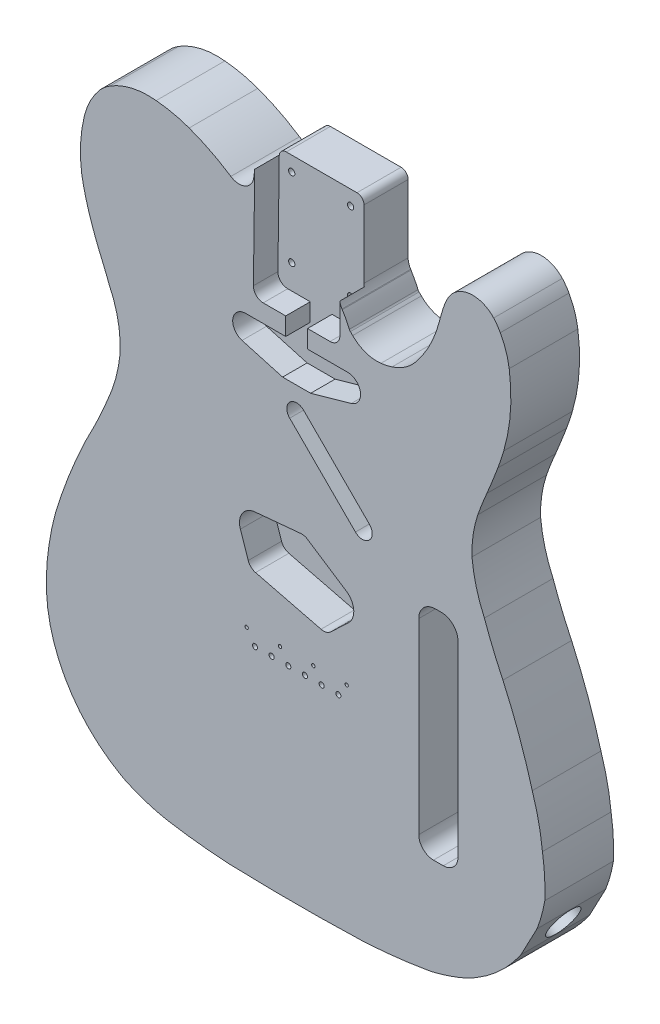
from build123d import *

# Parameters (mm, degrees)
EXTRUDE1_DEPTH     = 44.45
CUT_EXTRUDE1_DEPTH = 15.875
CUT_EXTRUDE2_DEPTH = 15.875
CUT_EXTRUDE3_DEPTH = 21.59
CUT_EXTRUDE4_DEPTH = 38.1
SKETCH7_R          = 2.032
SKETCH7_R_2        = 1.651
SKETCH7_R_3        = 1.0795
CUT_EXTRUDE5_DEPTH = 45.45
SKETCH9_R          = 10.4775
CUT_EXTRUDE6_DEPTH = 60.96


with BuildPart() as part:
    # Sketch1 → Extrude1 (new body)
    with BuildSketch(Plane.XY):
        with BuildLine():
            Line((292.199188308, -149.018420949), (292.199188308, -105.080789749))
            ThreePointArc((292.199188308, -105.080789749), (290.860080512, -101.847897546), (287.627188308, -100.508789749))
            Line((287.627188308, -100.508789749), (241.859817308, -100.508789749))
            ThreePointArc((241.859817308, -100.508789749), (238.832325903, -101.654789196), (237.322552553, -104.518284153))
            Line((237.322552553, -104.518284153), (236.701316073, -109.52926873))
            ThreePointArc((236.701316073, -109.52926873), (231.168774634, -117.069145619), (221.847963335, -116.306757925))
            ThreePointArc((221.847963335, -116.306757925), (208.754430906, -108.681109765), (194.846389938, -102.667999276))
            ThreePointArc((194.846389938, -102.667999276), (184.33706687, -99.609971872), (173.515607417, -97.968808186))
            ThreePointArc((173.515607417, -97.968808186), (158.033643634, -98.861943823), (143.665987646, -104.697983172))
            ThreePointArc((143.665987646, -104.697983172), (140.408838277, -107.058481962), (137.445598788, -109.778810669))
            ThreePointArc((137.445598788, -109.778810669), (131.043721763, -119.123880284), (127.035981804, -129.718802463))
            ThreePointArc((127.035981804, -129.718802463), (124.573432967, -146.269656884), (125.255619962, -162.988794116))
            ThreePointArc((125.255619962, -162.988794116), (127.242538349, -172.460797738), (129.825215128, -181.787987987))
            ThreePointArc((129.825215128, -181.787987987), (133.075015811, -191.465362925), (136.805999876, -200.967602033))
            ThreePointArc((136.805999876, -200.967602033), (140.009351293, -208.552159349), (143.036403771, -216.208785452))
            ThreePointArc((143.036403771, -216.208785452), (148.821671734, -233.475789286), (150.145583831, -251.638002906))
            ThreePointArc((150.145583831, -251.638002906), (147.267654281, -267.095111542), (141.885601169, -281.867998538))
            ThreePointArc((141.885601169, -281.867998538), (138.15011329, -290.562901746), (134.146412963, -299.137608457))
            ThreePointArc((134.146412963, -299.137608457), (121.785922582, -324.908171995), (111.535599896, -351.588399738))
            ThreePointArc((111.535599896, -351.588399738), (106.985107058, -366.822863837), (104.046020061, -382.448408598))
            ThreePointArc((104.046020061, -382.448408598), (102.647449975, -395.681700125), (102.514778175, -408.988029488))
            ThreePointArc((102.514778175, -408.988029488), (116.491997059, -454.558227502), (150.7976326, -487.650960312))
            ThreePointArc((150.7976326, -487.650960312), (153.132813702, -488.891966769), (155.529411112, -490.009772055))
            ThreePointArc((155.529411112, -490.009772055), (162.119332045, -492.66041759), (168.847113622, -494.938560412))
            ThreePointArc((168.847113622, -494.938560412), (175.41675582, -496.721647355), (182.091053802, -498.06080534))
            ThreePointArc((182.091053802, -498.06080534), (201.284365127, -500.712124037), (220.593569016, -502.314414768))
            ThreePointArc((220.593569016, -502.314414768), (221.005809518, -502.335099855), (221.418249918, -502.351317756))
            ThreePointArc((221.418249918, -502.351317756), (264.647051031, -503.080364835), (307.875618661, -502.337602376))
            ThreePointArc((307.875618661, -502.337602376), (328.927693445, -500.563755223), (349.837334812, -497.543277726))
            ThreePointArc((349.837334812, -497.543277726), (351.598276471, -497.203125432), (353.34611347, -496.801024785))
            ThreePointArc((353.34611347, -496.801024785), (361.755549825, -494.399047207), (369.979692546, -491.423884594))
            ThreePointArc((369.979692546, -491.423884594), (375.398528429, -489.000609473), (380.612291985, -486.162879004))
            ThreePointArc((380.612291985, -486.162879004), (396.681938677, -474.024490792), (409.729890716, -458.684185685))
            Line((409.729890716, -458.684185685), (420.094055916, -439.023188685))
            ThreePointArc((420.094055916, -439.023188685), (423.063561292, -430.01344484), (425.122156967, -420.753011255))
            ThreePointArc((425.122156967, -420.753011255), (425.004343862, -407.337993061), (423.600912787, -393.996067626))
            ThreePointArc((423.600912787, -393.996067626), (421.10111713, -378.394798828), (417, -363.136050363))
            ThreePointArc((417, -363.136050363), (408.529943954, -336.537553481), (398, -310.685238959))
            ThreePointArc((398, -310.685238959), (391.630728219, -296.430381849), (386, -281.867982529))
            ThreePointArc((386, -281.867982529), (380.726878313, -267.085540483), (377.952, -251.638001665))
            ThreePointArc((377.952, -251.638001665), (378.714214467, -238.675334685), (381.762, -226.053024696))
            ThreePointArc((381.762, -226.053024696), (384.539198732, -218.556898426), (387.604315044, -211.173822925))
            ThreePointArc((387.604315044, -211.173822925), (391.254222849, -202.284529655), (394.711732353, -193.318650453))
            ThreePointArc((394.711732353, -193.318650453), (396.712754261, -187.660629455), (398.51083823, -181.934881964))
            ThreePointArc((398.51083823, -181.934881964), (402.850474904, -158.142443784), (402.069055883, -133.970105351))
            ThreePointArc((402.069055883, -133.970105351), (399.985802716, -125.076495888), (396.320319987, -116.70986757))
            ThreePointArc((396.320319987, -116.70986757), (394.334175573, -113.548332568), (392.000790649, -110.63364768))
            ThreePointArc((392.000790649, -110.63364768), (377.452238099, -104.634981093), (363.691267002, -112.269118675))
            ThreePointArc((363.691267002, -112.269118675), (361.726956799, -115.496521241), (360.217685454, -118.960152558))
            ThreePointArc((360.217685454, -118.960152558), (358.444494216, -124.360677397), (356.931483202, -129.839789858))
            ThreePointArc((356.931483202, -129.839789858), (350.978861449, -145.938115534), (341.692412278, -160.372507003))
            ThreePointArc((341.692412278, -160.372507003), (334.73699249, -166.788775863), (326.235196527, -170.94399378))
            ThreePointArc((326.235196527, -170.94399378), (322.667875689, -171.899746908), (319.025876709, -172.512189097))
            ThreePointArc((319.025876709, -172.512189097), (309.134941175, -171.428010076), (300.736447938, -166.092153889))
            ThreePointArc((300.736447938, -166.092153889), (300.007266015, -165.356748256), (299.271136815, -164.6282968))
            ThreePointArc((299.271136815, -164.6282968), (298.881114017, -164.165142154), (298.586108838, -163.636368144))
            ThreePointArc((298.586108838, -163.636368144), (296.462851387, -159.222894193), (294.036002675, -154.968792661))
            ThreePointArc((294.036002675, -154.968792661), (293.913775031, -154.790050379), (293.795194926, -154.608867711))
            ThreePointArc((293.795194926, -154.608867711), (292.597959361, -151.927620431), (292.199188308, -149.018420949))
        make_face()
    extrude(amount=EXTRUDE1_DEPTH)

    # Sketch3 → Cut-Extrude1 (cut)
    with BuildSketch(Plane.XY.offset(44.45)):
        with BuildLine():
            Line((236.449845908, -170.314898549), (237.322552553, -104.518284153))
            ThreePointArc((237.322552553, -104.518284153), (238.832325903, -101.654789196), (241.859817308, -100.508789749))
            Line((241.859817308, -100.508789749), (287.627188308, -100.508789749))
            ThreePointArc((287.627188308, -100.508789749), (290.860080512, -101.847897546), (292.199188308, -105.080789749))
            Line((292.199188308, -105.080789749), (292.442550838, -170.3148977))
            ThreePointArc((292.442550838, -170.3148977), (290.616739776, -174.866113366), (286.093256908, -176.759589749))
            Line((286.093256908, -176.759589749), (271.507408508, -176.759589749))
            Line((271.507408508, -176.759589749), (271.507408508, -188.316589749))
            Line((271.507408508, -188.316589749), (297.505299108, -188.316589749))
            ThreePointArc((297.505299108, -188.316589749), (305.755367231, -195.487932258), (299.802423969, -204.656042419))
            Line((299.802423969, -204.656042419), (273.524828908, -212.065589749))
            Line((273.524828908, -212.065589749), (255.367537308, -212.065589749))
            Line((255.367537308, -212.065589749), (229.089966669, -204.656042138))
            ThreePointArc((229.089966669, -204.656042138), (223.137024456, -195.487931754), (231.387092508, -188.316589749))
            Line((231.387092508, -188.316589749), (257.385008508, -188.316589749))
            Line((257.385008508, -188.316589749), (257.385008508, -176.759589749))
            Line((257.385008508, -176.759589749), (242.799134708, -176.759589749))
            ThreePointArc((242.799134708, -176.759589749), (238.275655477, -174.866111836), (236.449845908, -170.314898549))
        make_face()
    extrude(amount=-CUT_EXTRUDE1_DEPTH, mode=Mode.SUBTRACT)

    # Sketch4 → Cut-Extrude2 (cut)
    with BuildSketch(Plane.XY.offset(44.45)):
        with BuildLine():
            Line((259.956078591, -232.811718112), (302.5224836, -275.3781386))
            ThreePointArc((302.5224836, -275.3781386), (311.5027425, -275.3781513), (311.5027552, -266.3978924))
            Line((311.5027552, -266.3978924), (268.936335809, -223.831463088))
            ThreePointArc((268.936335809, -223.831463088), (259.956079688, -223.831461991), (259.956078591, -232.811718112))
        make_face()
    extrude(amount=-CUT_EXTRUDE2_DEPTH, mode=Mode.SUBTRACT)

    # Sketch5 → Cut-Extrude3 (cut)
    with BuildSketch(Plane.XY.offset(44.45)):
        with BuildLine():
            Line((228.0253758, -311.0069726), (233.0908216, -326.0407246))
            ThreePointArc((233.0908216, -326.0407246), (234.905674363, -328.839037735), (237.841094697, -330.422563679))
            Line((237.841094697, -330.422563679), (280.248995, -340.9960414))
            ThreePointArc((280.248995, -340.9960414), (283.58425184, -340.975976581), (286.500413487, -339.357229523))
            Line((286.500413487, -339.357229523), (298.0308492, -328.4612938))
            ThreePointArc((298.0308492, -328.4612938), (301.409166684, -319.564297135), (296.527090326, -311.395153414))
            Line((296.527090326, -311.395153414), (271.5010572, -294.9508198))
            ThreePointArc((271.5010572, -294.9508198), (269.433129751, -294.04502602), (267.182014608, -293.873950251))
            Line((267.182014608, -293.873950251), (237.365174798, -296.644421471))
            ThreePointArc((237.365174798, -296.644421471), (229.219374538, -301.565359429), (228.0253758, -311.0069726))
        make_face()
    extrude(amount=-CUT_EXTRUDE3_DEPTH, mode=Mode.SUBTRACT)

    # Sketch6 → Cut-Extrude4 (cut)
    with BuildSketch(Plane.XY.offset(44.45)):
        with BuildLine():
            Line((354.3107976, -292.5743958), (358.1207976, -292.5743958))
            ThreePointArc((358.1207976, -292.5743958), (365.754015303, -295.736178097), (368.9157976, -303.3693958))
            Line((368.9157976, -303.3693958), (368.9157976, -424.5273704))
            ThreePointArc((368.9157976, -424.5273704), (366.125989691, -431.262562491), (359.3907976, -434.0523704))
            Line((359.3907976, -434.0523704), (353.0407976, -434.0523704))
            ThreePointArc((353.0407976, -434.0523704), (346.305605509, -431.262562491), (343.5157976, -424.5273704))
            Line((343.5157976, -424.5273704), (343.5157976, -303.3693958))
            ThreePointArc((343.5157976, -303.3693958), (346.677579897, -295.736178097), (354.3107976, -292.5743958))
        make_face()
    extrude(amount=-CUT_EXTRUDE4_DEPTH, mode=Mode.SUBTRACT)

    # Sketch7 → Cut-Extrude5 (cut, through all)
    with BuildSketch(Plane.XY.offset(44.45)):
        with Locations((245.397782, -110.0336128)):
            Circle(SKETCH7_R)
        with Locations((283.497782, -110.0336128)):
            Circle(SKETCH7_R)
        with Locations((283.497782, -160.8336128)):
            Circle(SKETCH7_R)
        with Locations((245.397782, -160.8336128)):
            Circle(SKETCH7_R)
        with Locations((237.4713818, -372.0851842)):
            Circle(SKETCH7_R_2)
        with Locations((248.2654166, -372.0851842)):
            Circle(SKETCH7_R_2)
        with Locations((259.0610008, -372.0851842)):
            Circle(SKETCH7_R_2)
        with Locations((269.8566104, -372.0851842)):
            Circle(SKETCH7_R_2)
        with Locations((280.6516104, -372.0851842)):
            Circle(SKETCH7_R_2)
        with Locations((291.446204, -372.0851842)):
            Circle(SKETCH7_R_2)
        with Locations((296.8433992, -363.957616)):
            Circle(SKETCH7_R_3)
        with Locations((275.2536024, -363.957616)):
            Circle(SKETCH7_R_3)
        with Locations((232.0733992, -363.957616)):
            Circle(SKETCH7_R_3)
        with Locations((253.6640088, -363.957616)):
            Circle(SKETCH7_R_3)
    extrude(amount=-CUT_EXTRUDE5_DEPTH, mode=Mode.SUBTRACT)

    # Sketch9 → Cut-Extrude6 (cut)
    with BuildSketch(Plane(origin=(509.846109655, -268.762021938, 0), x_dir=(0, 0, -1), z_dir=(0.884616289, -0.466319656, 0))):
        with Locations(Location((-22.225, -203.708, 0), (0, 0, 90))):  # turned: the seam where the file's is
            Circle(SKETCH9_R)
    extrude(amount=-CUT_EXTRUDE6_DEPTH, mode=Mode.SUBTRACT)


solid = part.part
